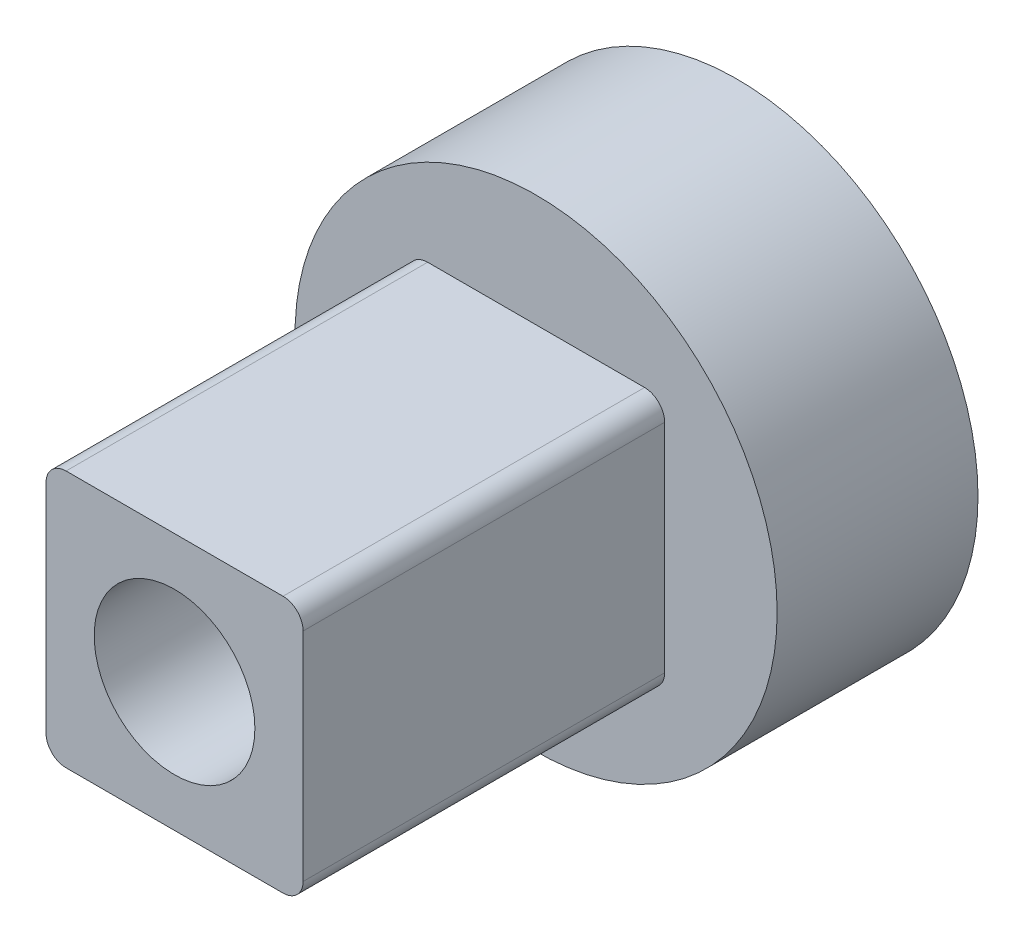
from build123d import *

# Parameters (mm, degrees)
SKETCH1_R           = 6
SKETCH1_R_2         = 2.4
BOSS_EXTRUDE1_DEPTH = 5
BOSS_EXTRUDE2_DEPTH = 9
CUT_EXTRUDE1_REACH  = 16
SKETCH3_R           = 1
SKETCH4_R           = 2
CUT_EXTRUDE2_DEPTH  = 7


with BuildPart() as part:
    # Sketch1 → Boss-Extrude1 (new body)
    with BuildSketch(Plane.XY.offset(-23.465471353)):
        with Locations((3.740457308, -31.828386779)):
            Circle(SKETCH1_R)
        with Locations((3.740457308, -31.828386779)):
            Circle(SKETCH1_R_2, mode=Mode.SUBTRACT)
    extrude(amount=BOSS_EXTRUDE1_DEPTH)

    # Sketch2 → Boss-Extrude2 (add)
    with BuildSketch(Plane.XY.offset(-18.465471353)):
        with BuildLine():
            Line((6.440457308, -28.628386779), (1.040457308, -28.628386779))
            ThreePointArc((1.040457308, -28.628386779), (0.686903918, -28.774833388), (0.540457308, -29.128386779))
            Line((0.540457308, -29.128386779), (0.540457308, -34.528386779))
            ThreePointArc((0.540457308, -34.528386779), (0.686903918, -34.881940169), (1.040457308, -35.028386779))
            Line((1.040457308, -35.028386779), (6.440457308, -35.028386779))
            ThreePointArc((6.440457308, -35.028386779), (6.794010699, -34.881940169), (6.940457308, -34.528386779))
            Line((6.940457308, -34.528386779), (6.940457308, -29.128386779))
            ThreePointArc((6.940457308, -29.128386779), (6.794010699, -28.774833388), (6.440457308, -28.628386779))
        make_face()
    extrude(amount=BOSS_EXTRUDE2_DEPTH)

    # Sketch3 → Cut-Extrude1 (cut, up to next)
    with BuildSketch(Plane.XY.offset(-9.465471353), mode=Mode.PRIVATE) as cut_extrude1_sk1:
        with Locations((3.740457264, -31.828386779)):
            Circle(SKETCH3_R)
    cut_extrude1_tool1 = extrude(cut_extrude1_sk1.sketch, amount=-CUT_EXTRUDE1_REACH, mode=Mode.PRIVATE) & part.part
    add(cut_extrude1_tool1.solids().sort_by_distance((3.740457, -31.828387, -9.465471))[0], mode=Mode.SUBTRACT)

    # Sketch4 → Cut-Extrude2 (cut)
    with BuildSketch(Plane.XY.offset(-9.465471353)):
        with Locations((3.740457264, -31.828386779)):
            Circle(SKETCH4_R)
    extrude(amount=-CUT_EXTRUDE2_DEPTH, mode=Mode.SUBTRACT)


solid = part.part
